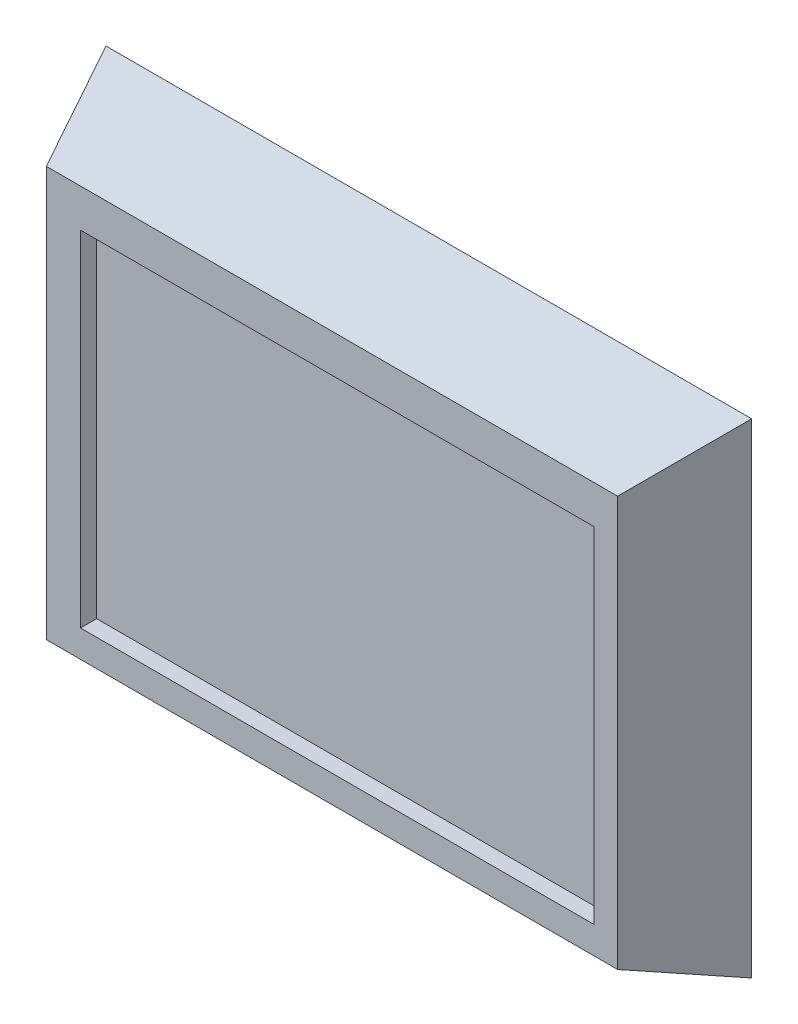
from build123d import *

# Parameters (mm, degrees)
IZIM1_W                     = 200
IZIM1_H                     = 150
Y_KSEKLIK_EKSTR_ZYON1_DEPTH = 30
Y_KSEKLIK_EKSTR_ZYON1_TAPER = 21
IZIM2_W                     = 159.102427113
IZIM2_H                     = 106.722832774
KES_EKSTR_ZYON1_DEPTH       = 5


with BuildPart() as part:
    # Çizim1 → Yükseklik-Ekstrüzyon1 (new body)
    with BuildSketch(Plane.XY):
        with Locations((100, 75)):
            Rectangle(IZIM1_W, IZIM1_H)
    extrude(amount=Y_KSEKLIK_EKSTR_ZYON1_DEPTH, taper=Y_KSEKLIK_EKSTR_ZYON1_TAPER)

    # Çizim2 → Kes-Ekstrüzyon1 (cut)
    with BuildSketch(Plane.XY.offset(30)):
        with Locations((101.653948212, 73.301492912)):
            Rectangle(IZIM2_W, IZIM2_H)
    extrude(amount=-KES_EKSTR_ZYON1_DEPTH, mode=Mode.SUBTRACT)


solid = part.part
